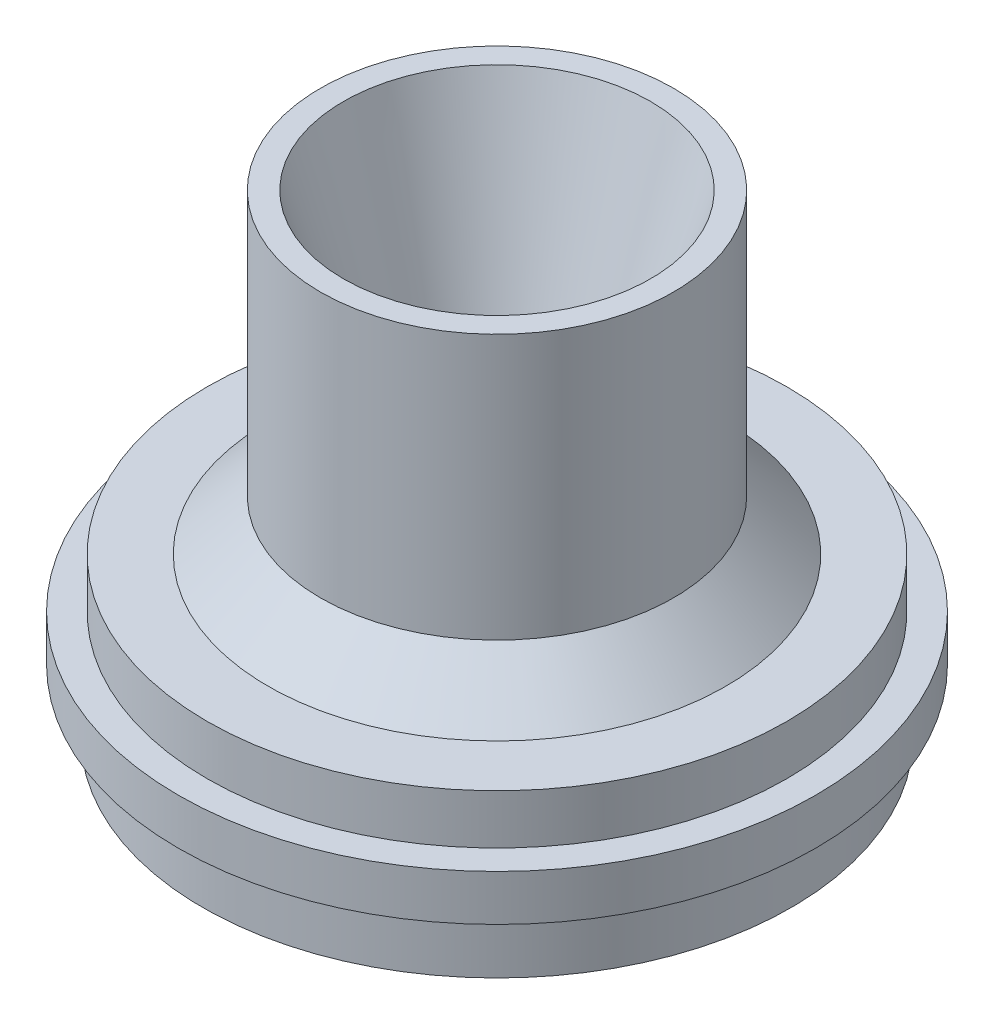
from build123d import *


with BuildPart() as part:
    # Sketch1 → Revolve1 (revolve)
    with BuildSketch(Plane.XY):
        Polygon((-22.098, 25.4), (-12.2555, -7.366), (-12.2555, -30.226), (-35.0647, -42.8244), (-42.318558906, -42.8244), (-42.318558906, -33.6804), (-45.8216, -33.6804), (-45.8216, -27.0764), (-41.6941, -27.0764), (-41.6941, -19.939), (-32.9311, -19.939), (-25.4, -12.7), (-25.4, 25.4), align=None)
    revolve(axis=Axis((0, 0, 0), (0, 1, 0)))


solid = part.part
